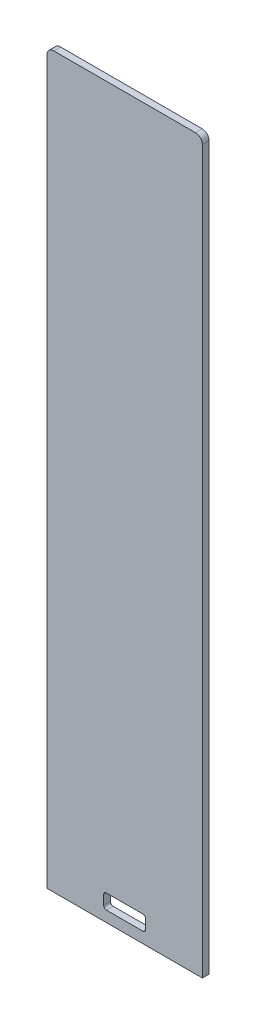
from build123d import *

# Parameters (mm, degrees)
SKETCH1_W           = 115
SKETCH1_H           = 499.2
BOSS_EXTRUDE1_DEPTH = 5
CUT_EXTRUDE1_REACH  = 7
SKETCH2_W           = 31
SKETCH2_H           = 11
FILLET1_R           = 2
SKETCH3_W           = 115
SKETCH3_H           = 40
BOSS_EXTRUDE2_DEPTH = 5
FILLET2_R           = 5


with BuildPart() as part:
    # Sketch1 → Boss-Extrude1 (new body)
    with BuildSketch(Plane.XY):
        with Locations((0, 249.6)):
            Rectangle(SKETCH1_W, SKETCH1_H)
    extrude(amount=BOSS_EXTRUDE1_DEPTH)

    # Sketch2 → Cut-Extrude1 (cut, up to next)
    with BuildSketch(Plane.XY.offset(5), mode=Mode.PRIVATE) as cut_extrude1_sk1:
        with Locations((0, 13.5)):
            Rectangle(SKETCH2_W, SKETCH2_H)
    cut_extrude1_tool1 = extrude(cut_extrude1_sk1.sketch, amount=-CUT_EXTRUDE1_REACH, mode=Mode.PRIVATE) & part.part
    add(cut_extrude1_tool1.solids().sort_by_distance((0, 13.5, 5))[0], mode=Mode.SUBTRACT)

    # Fillet1
    fillet1_edges = [part.edges().sort_by_distance(p)[0] for p in [
        (-15.5, 8, 2.5),
        (-15.5, 19, 2.5),
        (15.5, 19, 2.5),
        (15.5, 8, 2.5),
    ]]
    fillet(fillet1_edges, radius=FILLET1_R)

    # Sketch3 → Boss-Extrude2 (add)
    with BuildSketch(Plane.XY.offset(5)):
        with Locations((0, 519.2)):
            Rectangle(SKETCH3_W, SKETCH3_H)
    extrude(amount=-BOSS_EXTRUDE2_DEPTH)

    # Fillet2
    fillet2_edges = [part.edges().sort_by_distance(p)[0] for p in [
        (-57.5, 539.2, 2.5),
        (57.5, 539.2, 2.5),
    ]]
    fillet(fillet2_edges, radius=FILLET2_R)


solid = part.part
